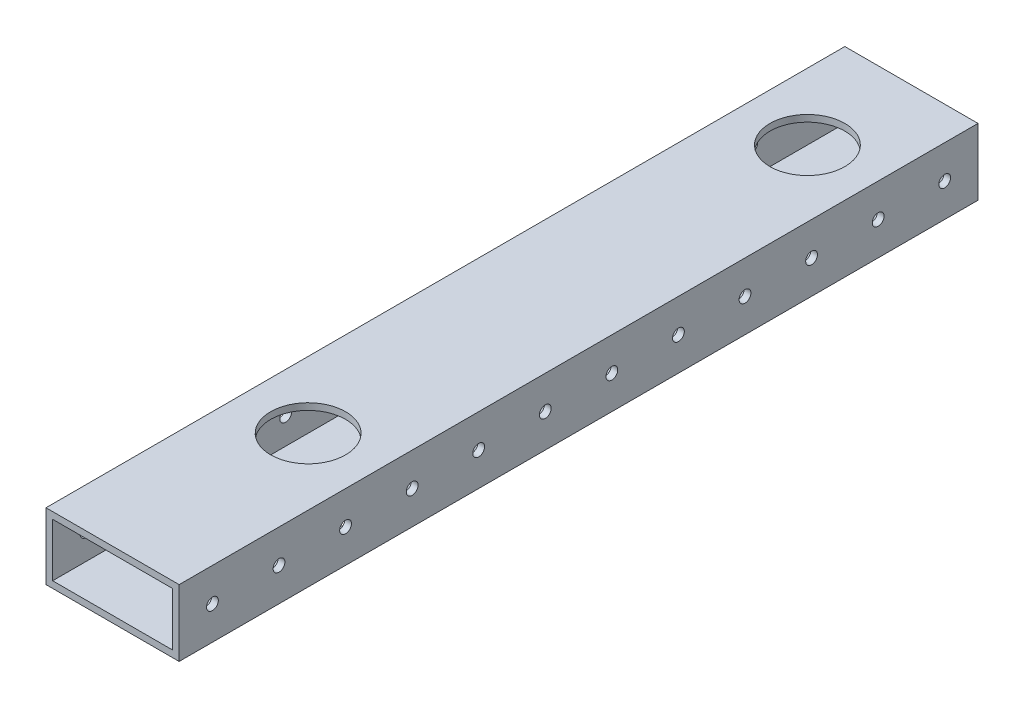
from build123d import *

# Parameters (mm, degrees)
SKETCH1_W             = 50.8
SKETCH1_H             = 25.4
SKETCH1_W_2           = 45.72
SKETCH1_H_2           = 20.32
BOSS_EXTRUDE1_DEPTH   = 533.4
F_8_CLEARANCE_HOLE1_D = 4.4958
CUT_EXTRUDE2_DEPTH    = 76.962
SKETCH5_R             = 14.2875
CUT_EXTRUDE3_DEPTH    = 43.434


with BuildPart() as part:
    # Sketch1 → Boss-Extrude1 (new body)
    with BuildSketch(Plane.XY):
        Rectangle(SKETCH1_W, SKETCH1_H)
        Rectangle(SKETCH1_W_2, SKETCH1_H_2, mode=Mode.SUBTRACT)
    extrude(amount=-BOSS_EXTRUDE1_DEPTH)

    # #8 Clearance Hole1 (through all)
    with Locations(Plane(origin=(25.4, 0, 0), x_dir=(0, 0, -1), z_dir=(1, 0, 0))):
        with Locations((12.7, 0), (38.1, 0), (63.5, 0), (88.9, 0), (114.3, 0), (139.7, 0), (165.1, 0), (190.5, 0), (215.9, 0), (241.3, 0), (266.7, 0), (292.1, 0), (317.5, 0), (342.9, 0), (368.3, 0), (393.7, 0), (419.1, 0), (444.5, 0), (469.9, 0), (495.3, 0), (520.7, 0)):
            Hole(F_8_CLEARANCE_HOLE1_D / 2)

    # Sketch4 → Cut-Extrude2 (cut)
    with BuildSketch(Plane(origin=(0, 12.7, 0), x_dir=(1, 0, 0), z_dir=(0, 1, 0))):
        Polygon((-7.206301081, 228.6), (135.513081356, 228.6), (135.513081356, -17.641370014), (-94.056886123, -17.641370014), (-94.056886123, 228.6), align=None)
    extrude(amount=-CUT_EXTRUDE2_DEPTH, mode=Mode.SUBTRACT)

    # Sketch5 → Cut-Extrude3 (cut)
    with BuildSketch(Plane(origin=(0, 12.7, 0), x_dir=(1, 0, 0), z_dir=(0, 1, 0))):
        with Locations((0, 493.7125)):
            Circle(SKETCH5_R)
        with Locations((0, 303.2125)):
            Circle(SKETCH5_R)
    extrude(amount=-CUT_EXTRUDE3_DEPTH, mode=Mode.SUBTRACT)


solid = part.part
